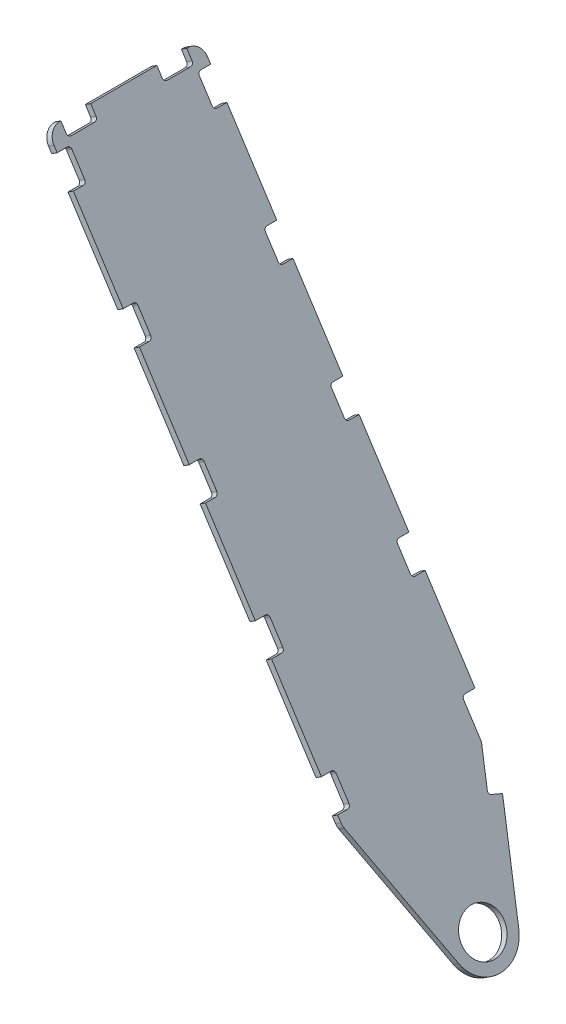
from build123d import *

# Parameters (mm, degrees)
SKETCH1_R           = 42.291
BOSS_EXTRUDE1_DEPTH = 12.7


with BuildPart() as part:
    # Sketch1 → Boss-Extrude1 (new body)
    with BuildSketch(Plane(origin=(106.603890681, 69.014006689, 0), x_dir=(-0.543445635, 0.839444365, 0), z_dir=(0.839444365, 0.543445635, 0))):
        with BuildLine():
            Line((2433.75688, -117.142768), (2433.75688, -136.700768))
            Line((2433.75688, -136.700768), (2445.44088, -136.700768))
            ThreePointArc((2445.44088, -136.700768), (2463.401392242, -129.261280242), (2470.84088, -111.300768))
            Line((2470.84088, -111.300768), (2470.84088, -109.141768))
            Line((2470.84088, -109.141768), (2451.28288, -109.141768))
            ThreePointArc((2451.28288, -109.141768), (2446.792751939, -107.28189606), (2444.93288, -102.791768))
            Line((2444.93288, -102.791768), (2444.93288, -56.309772))
            ThreePointArc((2444.93288, -56.309772), (2446.792751939, -51.819643939), (2451.28288, -49.959772))
            Line((2451.28288, -49.959772), (2470.84088, -49.959772))
            Line((2470.84088, -49.959772), (2470.84088, 81.358228))
            Line((2470.84088, 81.358228), (2451.28288, 81.358228))
            ThreePointArc((2451.28288, 81.358228), (2446.792751939, 83.21809994), (2444.93288, 87.708228))
            Line((2444.93288, 87.708228), (2444.93288, 134.190232))
            ThreePointArc((2444.93288, 134.190232), (2446.792751939, 138.680360061), (2451.28288, 140.540232))
            Line((2451.28288, 140.540232), (2470.84088, 140.540232))
            Line((2470.84088, 140.540232), (2470.84088, 142.699232))
            ThreePointArc((2470.84088, 142.699232), (2463.401392242, 160.659744242), (2445.44088, 168.099232))
            Line((2445.44088, 168.099232), (2433.75688, 168.099232))
            Line((2433.75688, 168.099232), (2433.75688, 148.541232))
            ThreePointArc((2433.75688, 148.541232), (2431.897008061, 144.051103939), (2427.40688, 142.191232))
            Line((2427.40688, 142.191232), (2380.92488, 142.191232))
            ThreePointArc((2380.92488, 142.191232), (2376.434751939, 144.051103939), (2374.57488, 148.541232))
            Line((2374.57488, 148.541232), (2374.57488, 168.099232))
            Line((2374.57488, 168.099232), (2192.45688, 168.099232))
            Line((2192.45688, 168.099232), (2192.45688, 148.541232))
            ThreePointArc((2192.45688, 148.541232), (2190.597008061, 144.051103939), (2186.10688, 142.191232))
            Line((2186.10688, 142.191232), (2139.62488, 142.191232))
            ThreePointArc((2139.62488, 142.191232), (2135.134751939, 144.051103939), (2133.27488, 148.541232))
            Line((2133.27488, 148.541232), (2133.27488, 168.099232))
            Line((2133.27488, 168.099232), (1951.15688, 168.099232))
            Line((1951.15688, 168.099232), (1951.15688, 148.541232))
            ThreePointArc((1951.15688, 148.541232), (1949.297008061, 144.051103939), (1944.80688, 142.191232))
            Line((1944.80688, 142.191232), (1898.32488, 142.191232))
            ThreePointArc((1898.32488, 142.191232), (1893.834751939, 144.051103939), (1891.97488, 148.541232))
            Line((1891.97488, 148.541232), (1891.97488, 168.099232))
            Line((1891.97488, 168.099232), (1709.85688, 168.099232))
            Line((1709.85688, 168.099232), (1709.85688, 148.541232))
            ThreePointArc((1709.85688, 148.541232), (1707.997008061, 144.051103939), (1703.50688, 142.191232))
            Line((1703.50688, 142.191232), (1657.02488, 142.191232))
            ThreePointArc((1657.02488, 142.191232), (1652.534751939, 144.051103939), (1650.67488, 148.541232))
            Line((1650.67488, 148.541232), (1650.67488, 168.099232))
            Line((1650.67488, 168.099232), (1468.55688, 168.099232))
            Line((1468.55688, 168.099232), (1468.55688, 148.541232))
            ThreePointArc((1468.55688, 148.541232), (1466.697008061, 144.051103939), (1462.20688, 142.191232))
            Line((1462.20688, 142.191232), (1415.72488, 142.191232))
            ThreePointArc((1415.72488, 142.191232), (1411.234751939, 144.051103939), (1409.37488, 148.541232))
            Line((1409.37488, 148.541232), (1409.37488, 168.099232))
            Line((1409.37488, 168.099232), (1397.098564625, 168.099232))
            ThreePointArc((1397.098564625, 168.099232), (1392.687900912, 167.713348927), (1388.411252984, 166.567424568))
            Line((1388.411252984, 166.567424568), (1137.847600899, 75.36971342))
            ThreePointArc((1137.847600899, 75.36971342), (1096.06588, 15.699232), (1137.847600899, -43.97124942))
            Line((1137.847600899, -43.97124942), (1317.752937975, -109.451437101))
            Line((1317.752937975, -109.451437101), (1324.442167938, -91.072928824))
            ThreePointArc((1324.442167938, -91.072928824), (1327.725590118, -87.489702286), (1332.58104399, -87.277708592))
            Line((1332.58104399, -87.277708592), (1396.135987148, -110.409816142))
            ThreePointArc((1396.135987148, -110.409816142), (1397.20514913, -110.696297232), (1398.307815058, -110.792768))
            Line((1398.307815058, -110.792768), (1462.20688, -110.792768))
            ThreePointArc((1462.20688, -110.792768), (1466.697008061, -112.652639939), (1468.55688, -117.142768))
            Line((1468.55688, -117.142768), (1468.55688, -136.700768))
            Line((1468.55688, -136.700768), (1650.67488, -136.700768))
            Line((1650.67488, -136.700768), (1650.67488, -117.142768))
            ThreePointArc((1650.67488, -117.142768), (1652.534751939, -112.652639939), (1657.02488, -110.792768))
            Line((1657.02488, -110.792768), (1703.50688, -110.792768))
            ThreePointArc((1703.50688, -110.792768), (1707.997008061, -112.652639939), (1709.85688, -117.142768))
            Line((1709.85688, -117.142768), (1709.85688, -136.700768))
            Line((1709.85688, -136.700768), (1891.97488, -136.700768))
            Line((1891.97488, -136.700768), (1891.97488, -117.142768))
            ThreePointArc((1891.97488, -117.142768), (1893.834751939, -112.652639939), (1898.32488, -110.792768))
            Line((1898.32488, -110.792768), (1944.80688, -110.792768))
            ThreePointArc((1944.80688, -110.792768), (1949.297008061, -112.652639939), (1951.15688, -117.142768))
            Line((1951.15688, -117.142768), (1951.15688, -136.700768))
            Line((1951.15688, -136.700768), (2133.27488, -136.700768))
            Line((2133.27488, -136.700768), (2133.27488, -117.142768))
            ThreePointArc((2133.27488, -117.142768), (2135.134751939, -112.652639939), (2139.62488, -110.792768))
            Line((2139.62488, -110.792768), (2186.10688, -110.792768))
            ThreePointArc((2186.10688, -110.792768), (2190.597008061, -112.652639939), (2192.45688, -117.142768))
            Line((2192.45688, -117.142768), (2192.45688, -136.700768))
            Line((2192.45688, -136.700768), (2374.57488, -136.700768))
            Line((2374.57488, -136.700768), (2374.57488, -117.142768))
            ThreePointArc((2374.57488, -117.142768), (2376.434751939, -112.652639939), (2380.92488, -110.792768))
            Line((2380.92488, -110.792768), (2427.40688, -110.792768))
            ThreePointArc((2427.40688, -110.792768), (2431.897008061, -112.652639939), (2433.75688, -117.142768))
        make_face()
        with Locations(Location((1159.56588, 15.699232, 0), (0, 0, 180))):  # turned: the seam where the file's is
            Circle(SKETCH1_R, mode=Mode.SUBTRACT)
    extrude(amount=-BOSS_EXTRUDE1_DEPTH)


solid = part.part
